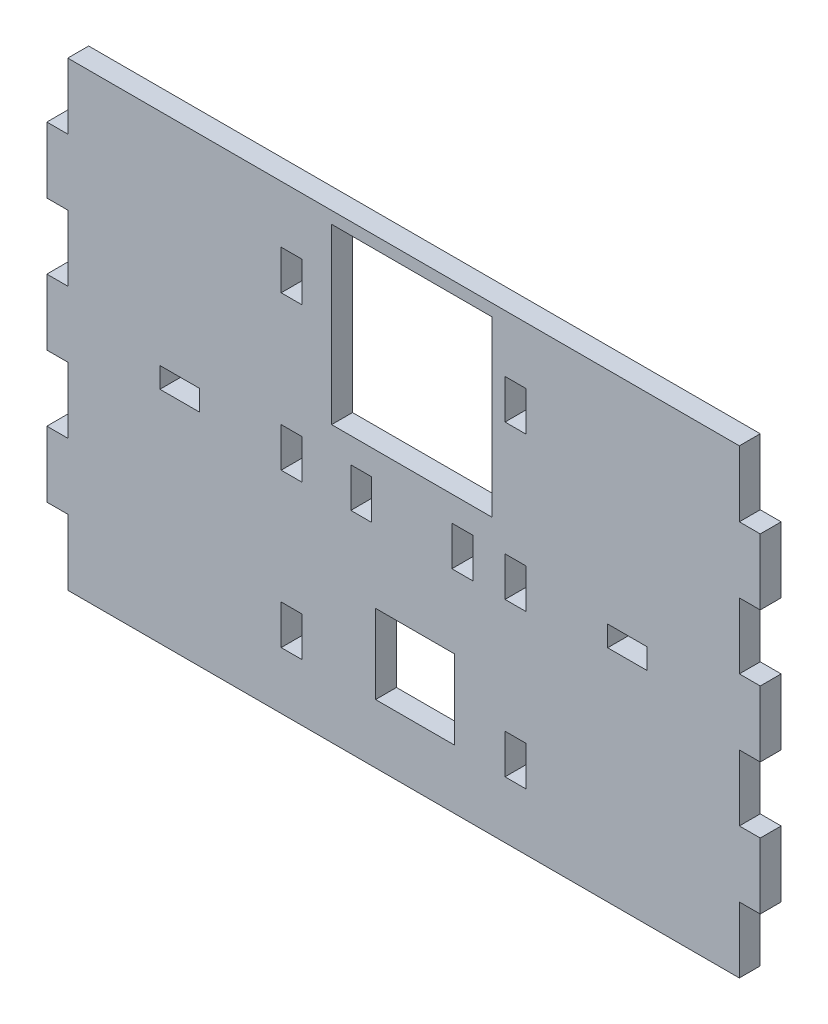
from build123d import *

# Parameters (mm, degrees)
SKETCH1_W           = 6
SKETCH1_H           = 3.125
SKETCH1_W_2         = 3.175
SKETCH1_H_2         = 6
BOSS_EXTRUDE1_DEPTH = 1.5875


with BuildPart() as part:
    # Sketch1 → Boss-Extrude1 (new body, symmetric)
    with BuildSketch(Plane.XY):
        Polygon((54.175, 0), (54.175, 5), (51, 5), (51, 15), (54.175, 15), (54.175, 25), (51, 25), (51, 35), (17, 35), (0, 35), (-17, 35), (-51, 35), (-51, 25), (-54.175, 25), (-54.175, 15), (-51, 15), (-51, 5), (-54.175, 5), (-54.175, -5), (-51, -5), (-51, -15), (-54.175, -15), (-54.175, -25), (-51, -25), (-51, -35), (0, -35), (51, -35), (51, -25), (54.175, -25), (54.175, -15), (51, -15), (51, -5), (54.175, -5), align=None)
        Polygon((-18.5875, -23.333333333), (-18.5875, -20.333333333), (-15.4125, -20.333333333), (-15.4125, -26.333333333), (-18.5875, -26.333333333), align=None, mode=Mode.SUBTRACT)
        Polygon((-4.247592219, -14), (3.252407781, -14), (7.752407781, -14), (7.752407781, -26), (3.252407781, -26), (-4.247592219, -26), align=None, mode=Mode.SUBTRACT)
        Polygon((18.5875, -20.333333333), (18.5875, -23.333333333), (18.5875, -26.333333333), (15.4125, -26.333333333), (15.4125, -20.333333333), align=None, mode=Mode.SUBTRACT)
        with Locations((-34, 0)):
            Rectangle(SKETCH1_W, SKETCH1_H, mode=Mode.SUBTRACT)
        with Locations((-17, 0)):
            Rectangle(SKETCH1_W_2, SKETCH1_H_2, mode=Mode.SUBTRACT)
        with Locations((-6.422592219, 0)):
            Rectangle(SKETCH1_W_2, SKETCH1_H_2, mode=Mode.SUBTRACT)
        Polygon((-18.5875, 20.333333333), (-18.5875, 23.333333333), (-18.5875, 26.333333333), (-15.4125, 26.333333333), (-15.4125, 20.333333333), align=None, mode=Mode.SUBTRACT)
        with Locations((8.927407781, 0)):
            Rectangle(SKETCH1_W_2, SKETCH1_H_2, mode=Mode.SUBTRACT)
        with Locations((17, 0)):
            Rectangle(SKETCH1_W_2, SKETCH1_H_2, mode=Mode.SUBTRACT)
        Polygon((37, 1.5625), (37, 0), (37, -1.5625), (31, -1.5625), (31, 1.5625), align=None, mode=Mode.SUBTRACT)
        Polygon((-10.922592219, 33.175), (3.252407781, 33.175), (13.427407781, 33.175), (13.427407781, 6.825), (1.252407781, 6.825), (-10.922592219, 6.825), align=None, mode=Mode.SUBTRACT)
        Polygon((18.5875, 23.333333333), (18.5875, 20.333333333), (15.4125, 20.333333333), (15.4125, 26.333333333), (18.5875, 26.333333333), align=None, mode=Mode.SUBTRACT)
    extrude(amount=BOSS_EXTRUDE1_DEPTH, both=True)


solid = part.part
